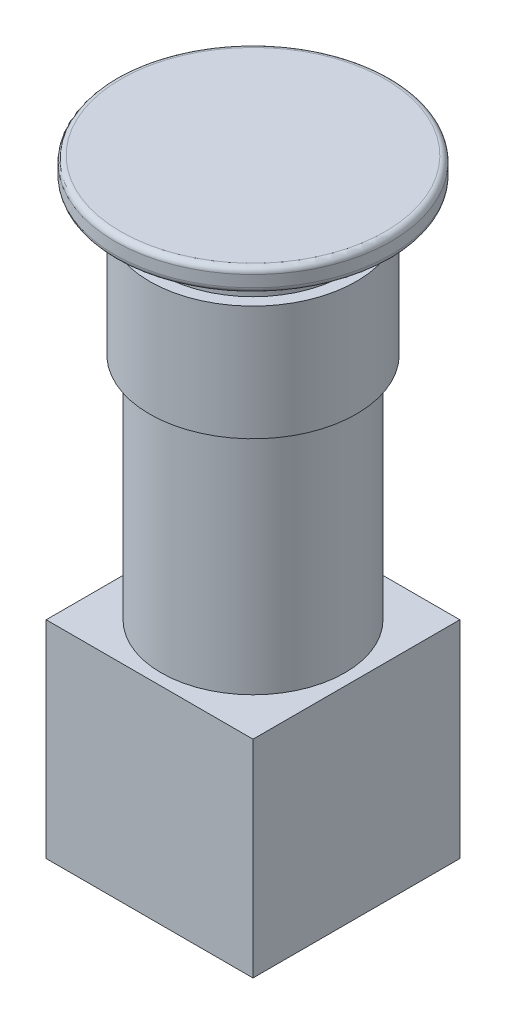
from build123d import *

# Parameters (mm, degrees)
ESQUISSE1_W        = 18
ESQUISSE1_H        = 18
BOSS_EXTRU_1_DEPTH = 18
ESQUISSE2_R        = 8
BOSS_EXTRU_2_DEPTH = 20
ESQUISSE3_R        = 9
BOSS_EXTRU_3_DEPTH = 10
ESQUISSE4_R        = 8
BOSS_EXTRU_4_DEPTH = 3
ESQUISSE5_R        = 12
BOSS_EXTRU_5_DEPTH = 2
CONG_1_R           = 0.5
CONG_2_R           = 0.5


with BuildPart() as part:
    # Esquisse1 → Boss.-Extru.1 (new body)
    with BuildSketch(Plane(origin=(0, 0, 0), x_dir=(1, 0, 0), z_dir=(0, 1, 0))):
        Rectangle(ESQUISSE1_W, ESQUISSE1_H)
    extrude(amount=BOSS_EXTRU_1_DEPTH)

    # Esquisse2 → Boss.-Extru.2 (add)
    with BuildSketch(Plane(origin=(0, 18, 0), x_dir=(1, 0, 0), z_dir=(0, 1, 0))):
        Circle(ESQUISSE2_R)
    extrude(amount=BOSS_EXTRU_2_DEPTH)

    # Esquisse3 → Boss.-Extru.3 (add)
    with BuildSketch(Plane(origin=(0, 38, 0), x_dir=(1, 0, 0), z_dir=(0, 1, 0))):
        Circle(ESQUISSE3_R)
    extrude(amount=BOSS_EXTRU_3_DEPTH)

    # Esquisse4 → Boss.-Extru.4 (add)
    with BuildSketch(Plane(origin=(0, 48, 0), x_dir=(1, 0, 0), z_dir=(0, 1, 0))):
        Circle(ESQUISSE4_R)
    extrude(amount=BOSS_EXTRU_4_DEPTH)

    # Esquisse5 → Boss.-Extru.5 (add)
    with BuildSketch(Plane(origin=(0, 51, 0), x_dir=(1, 0, 0), z_dir=(0, 1, 0))):
        Circle(ESQUISSE5_R)
    extrude(amount=BOSS_EXTRU_5_DEPTH)

    # Congé1
    cong_1_edges = [part.edges().sort_by_distance(p)[0] for p in [
        (-12, 53, 0),
    ]]
    fillet(cong_1_edges, radius=CONG_1_R)

    # Congé2
    cong_2_edges = [part.edges().sort_by_distance(p)[0] for p in [
        (-12, 51, 0),
    ]]
    fillet(cong_2_edges, radius=CONG_2_R)


solid = part.part
